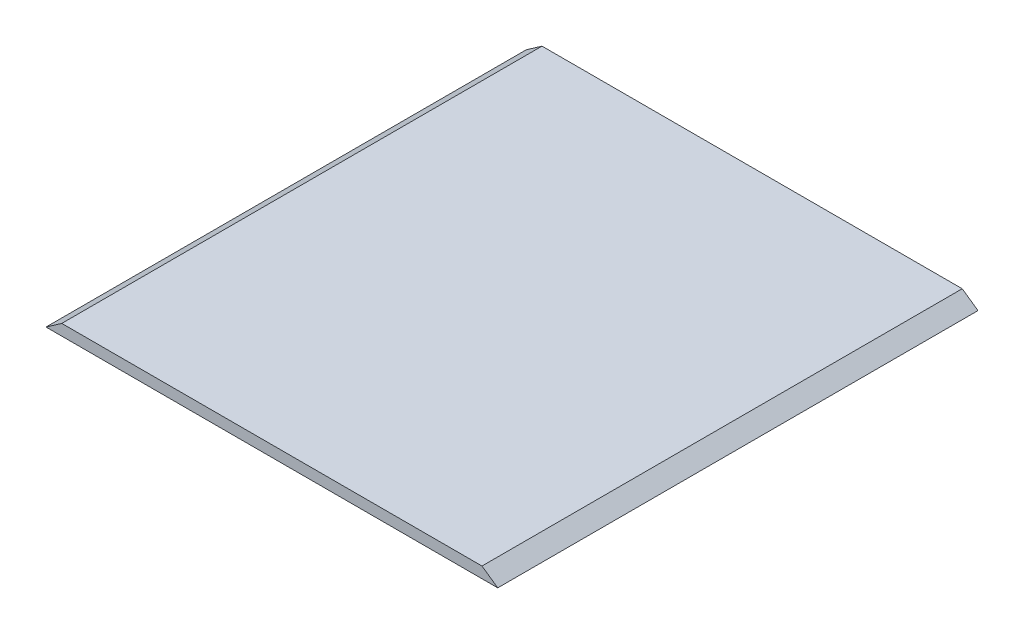
from build123d import *

# Parameters (mm, degrees)
ESBO_O1_W                = 175
ESBO_O1_H                = 4.6
RESSALTO_EXTRUS_O1_DEPTH = 200


with BuildPart() as part:
    # Esboço1 → Ressalto-extrusão1 (new body)
    with BuildSketch(Plane.XY):
        Polygon((-87.5, -2.3), (-87.5, 2.3), (-94.069480831, -2.3), align=None)
        Rectangle(ESBO_O1_W, ESBO_O1_H)
        Polygon((87.5, -2.3), (87.5, 2.3), (94.069480831, -2.3), align=None)
    extrude(amount=RESSALTO_EXTRUS_O1_DEPTH)


solid = part.part
